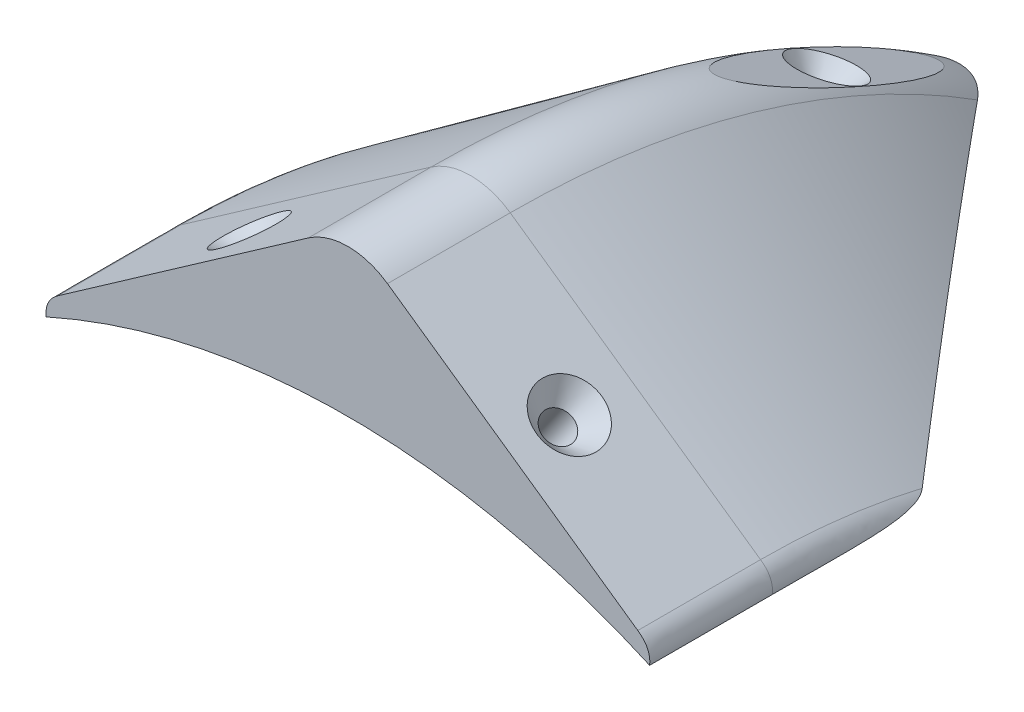
from build123d import *

# Parameters (mm, degrees)
REVOLVE1_ANGLE      = 57
BOSS_EXTRUDE1_DEPTH = 25.4
SKETCH8_R           = 152.4
CUT_EXTRUDE3_DEPTH  = 257.048
SKETCH13_W          = 16.387620484
SKETCH13_H          = 127
CUT_EXTRUDE5_DEPTH  = 1.778


with BuildPart() as part:
    # Sketch1 → Revolve1 (revolve)
    with BuildSketch(Plane.XY):
        with BuildLine():
            Line((-59.991213716, 144.035687339), (-8.193810242, 180.296949153))
            ThreePointArc((-8.193810242, 180.296949153), (0, 182.88), (8.193810242, 180.296949153))
            Line((8.193810242, 180.296949153), (59.991213716, 144.035687339))
            add(Edge.make_bspline(
                [(59.991213716, 144.035687339), (62.78248672, 142.0840471), (62.441206007, 139.021062406)],
                knots=[0, 0, 0, 1, 1, 1], degree=2))
            ThreePointArc((62.441206007, 139.021062406), (0, 152.4), (-62.441206007, 139.021062406))
            add(Edge.make_bspline(
                [(-59.991213716, 144.035687339), (-62.78248672, 142.0840471), (-62.441206007, 139.021062406)],
                knots=[0, 0, 0, 1, 1, 1], degree=2))
        make_face()
    revolve(axis=Axis((0, 0, 0), (-1, 0, 0)), revolution_arc=REVOLVE1_ANGLE)

    # Sketch3 → Boss-Extrude1 (add)
    with BuildSketch(Plane.XY):
        with BuildLine():
            Line((-59.991213716, 144.035687339), (-8.193810242, 180.296949153))
            ThreePointArc((-8.193810242, 180.296949153), (0, 182.88), (8.193810242, 180.296949153))
            Line((8.193810242, 180.296949153), (59.991213716, 144.035687339))
            add(Edge.make_bspline(
                [(59.991213716, 144.035687339), (62.78248672, 142.0840471), (62.441206007, 139.021062406)],
                knots=[0, 0, 0, 1, 1, 1], degree=2))
            ThreePointArc((62.441206007, 139.021062406), (0, 152.4), (-62.441206007, 139.021062406))
            add(Edge.make_bspline(
                [(-59.991213716, 144.035687339), (-62.78248672, 142.0840471), (-62.441206007, 139.021062406)],
                knots=[0, 0, 0, 1, 1, 1], degree=2))
        make_face()
    extrude(amount=BOSS_EXTRUDE1_DEPTH)

    # Sketch7 → Cut-Revolve2 (revolve, cut)
    with BuildSketch(Plane.XY.offset(12.7)):
        Polygon((-18.85509192, 148.029004366), (-21.456080621, 146.208157646), (-33.109499632, 162.854485329), (-27.584999632, 166.721963764), (-28.163260355, 161.325258604), align=None)
    cut_revolve2 = revolve(axis=Axis((-21.456080621, 146.208157646, 12.7), (-0.57349503, 0.81920904, 0)), mode=Mode.SUBTRACT)

    # Mirror2: Cut-Revolve2 across plane
    add(cut_revolve2.mirror(Plane(origin=(0, 0, 0), x_dir=(0, 0, 1), z_dir=(1, 0, 0))), mode=Mode.SUBTRACT)

    # Sketch8 → Cut-Extrude3 (cut)
    with BuildSketch(Plane.XY.offset(25.4)):
        Circle(SKETCH8_R)
    extrude(amount=-CUT_EXTRUDE3_DEPTH, mode=Mode.SUBTRACT)

    # Sketch13 → Cut-Extrude5 (cut)
    with BuildSketch(Plane(origin=(0, 167.069193294, -74.383997286), x_dir=(1, 0, 0), z_dir=(0, 0.913545458, -0.406736643))):
        Rectangle(SKETCH13_W, SKETCH13_H)
    extrude(amount=-CUT_EXTRUDE5_DEPTH, mode=Mode.SUBTRACT)

    # Sketch14 → Cut-Revolve4 (revolve, cut)
    with BuildSketch(Plane(origin=(0, 0, 0), x_dir=(0, 0, -1), z_dir=(1, 0, 0))):
        Polygon((73.660819534, 165.44490947), (67.500143032, 168.18781937), (69.097003878, 163.000445517), (60.429201972, 143.532243688), (63.3297088, 142.240854846), align=None)
    revolve(axis=Axis((0, 165.44490947, -73.660819534), (0, -0.913545458, 0.406736643)), mode=Mode.SUBTRACT)


solid = part.part
